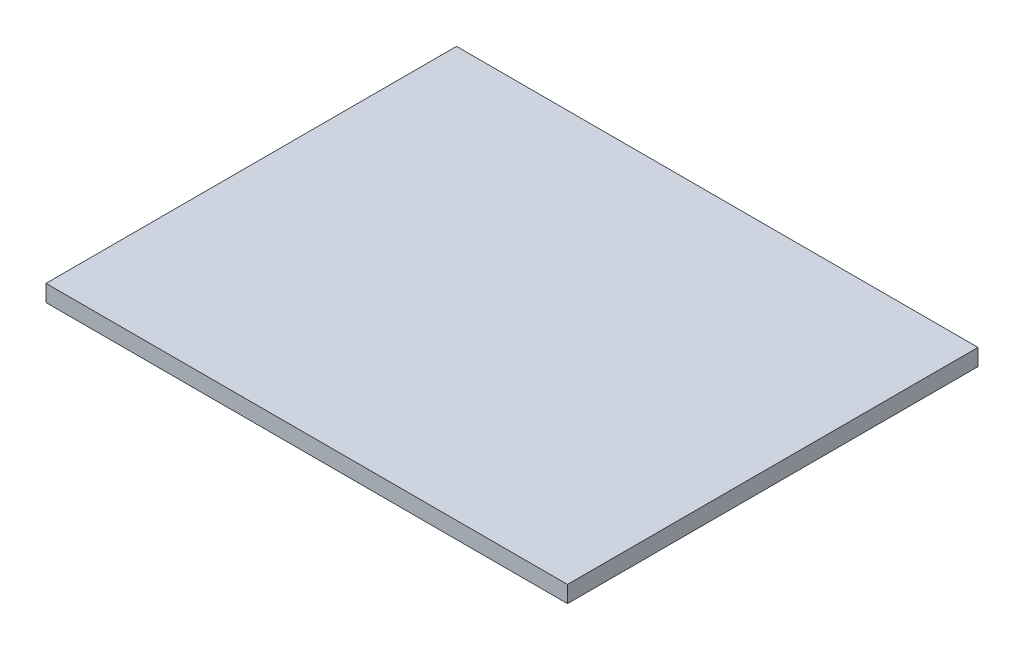
from build123d import *

# Parameters (mm, degrees)
SKETCH1_W           = 94
SKETCH1_H           = 74
BOSS_EXTRUDE1_DEPTH = 3


with BuildPart() as part:
    # Sketch1 → Boss-Extrude1 (new body)
    with BuildSketch(Plane(origin=(0, 0, 0), x_dir=(1, 0, 0), z_dir=(0, 1, 0))):
        Rectangle(SKETCH1_W, SKETCH1_H)
    extrude(amount=BOSS_EXTRUDE1_DEPTH)


solid = part.part
